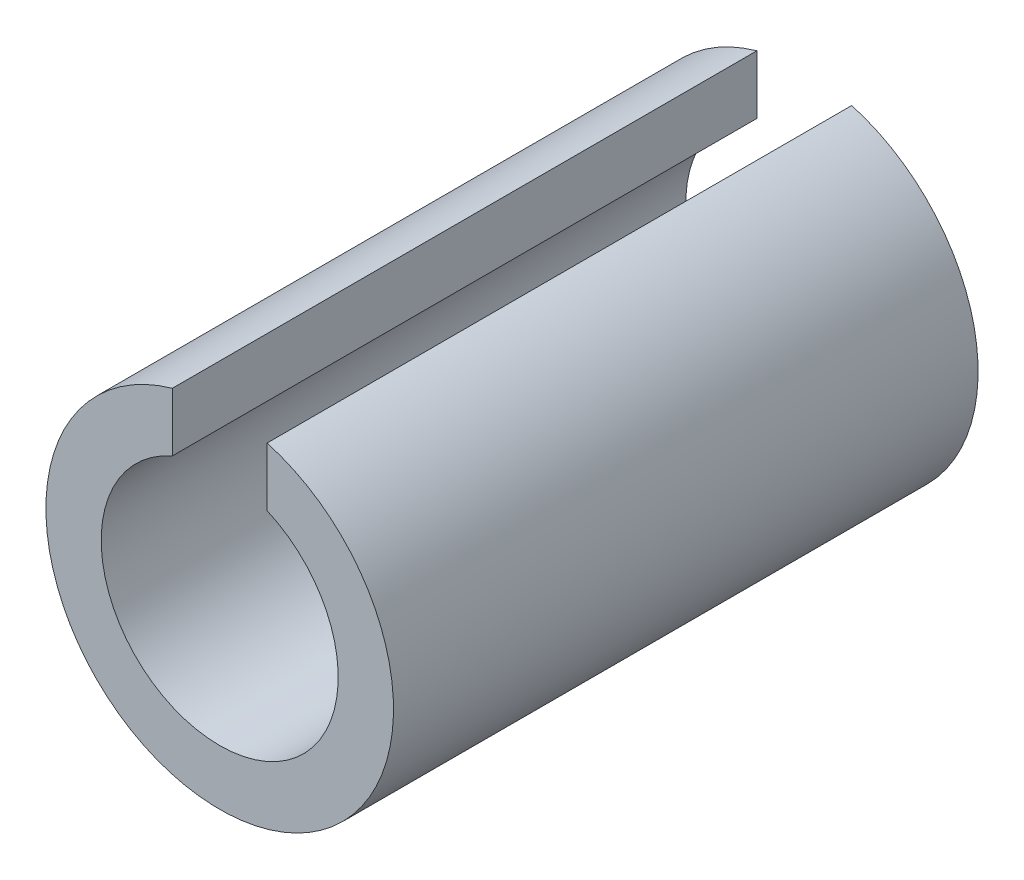
from build123d import *

# Parameters (mm, degrees)
EXTRUDE_1_DEPTH     = 37
CUT_EXTRUDE_1_DEPTH = 3


with BuildPart() as part:
    # Эскиз1 → Бобышка-Вытянуть1 (new body)
    with BuildSketch(Plane.XY):
        with BuildLine():
            Line((-3, 6.873863542), (-3, 10.583005244))
            ThreePointArc((-3, 10.583005244), (0, -11), (3, 10.583005244))
            Line((3, 10.583005244), (3, 6.873863542))
            ThreePointArc((3, 6.873863542), (0, -7.5), (-3, 6.873863542))
        make_face()
    extrude(amount=-EXTRUDE_1_DEPTH)

    # Эскиз2 → Вырез-Вытянуть1 (cut)
    with BuildSketch(Plane(origin=(0, -11, 0), x_dir=(-1, 0, 0), z_dir=(0, -1, 0))):
        with BuildLine():
            Line((3, 31), (3, 6))
            ThreePointArc((3, 6), (0, 3), (-3, 6))
            Line((-3, 6), (-3, 31))
            ThreePointArc((-3, 31), (0, 34), (3, 31))
        make_face()
    extrude(amount=-CUT_EXTRUDE_1_DEPTH, mode=Mode.SUBTRACT)


solid = part.part
